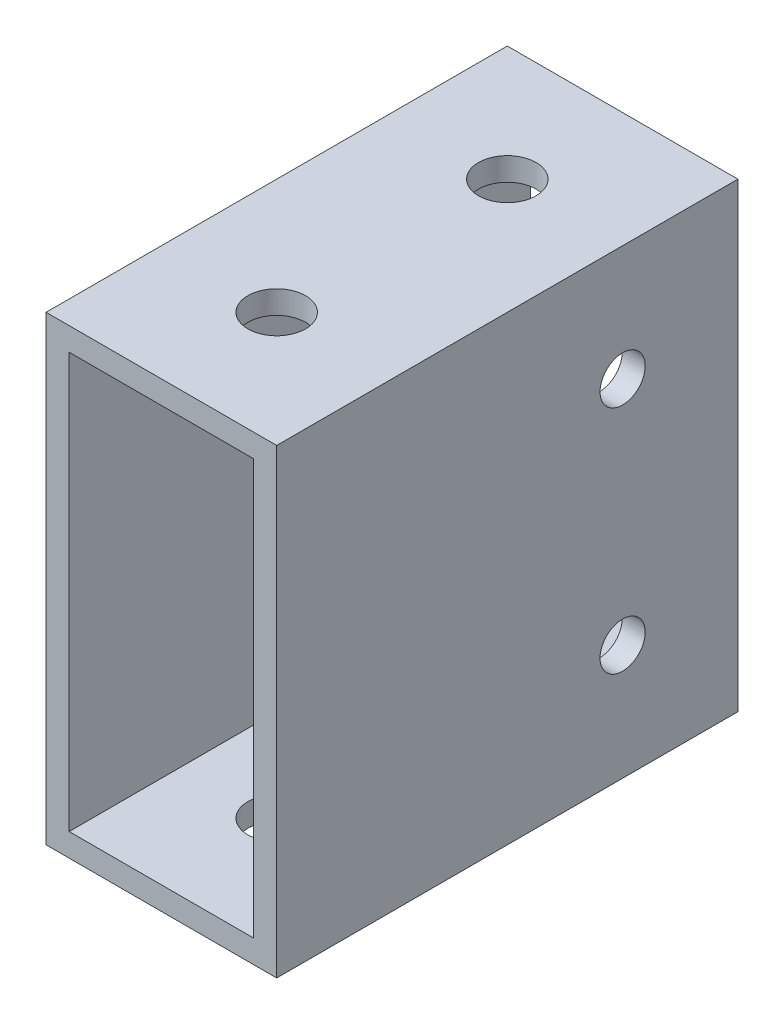
from build123d import *

# Parameters (mm, degrees)
SKETCH1_W           = 25.4
SKETCH1_H           = 50.8
SKETCH1_W_2         = 20.32
SKETCH1_H_2         = 45.72
EXTRUDE_THIN1_DEPTH = 25.4
SKETCH2_R           = 3.175
CUT_EXTRUDE1_DEPTH  = 51.8
SKETCH3_R           = 2.4892
CUT_EXTRUDE2_DEPTH  = 26.4


with BuildPart() as part:
    # Sketch1 → Extrude-Thin1 (new body, symmetric)
    with BuildSketch(Plane.XY):
        Rectangle(SKETCH1_W, SKETCH1_H)
        Rectangle(SKETCH1_W_2, SKETCH1_H_2, mode=Mode.SUBTRACT)
    extrude(amount=EXTRUDE_THIN1_DEPTH, both=True)

    # Sketch2 → Cut-Extrude1 (cut, through all)
    with BuildSketch(Plane(origin=(0, 25.4, 0), x_dir=(1, 0, 0), z_dir=(0, 1, 0))):
        with Locations((0, 12.7)):
            Circle(SKETCH2_R)
        with Locations((0, -12.7)):
            Circle(SKETCH2_R)
    extrude(amount=-CUT_EXTRUDE1_DEPTH, mode=Mode.SUBTRACT)

    # Sketch3 → Cut-Extrude2 (cut, through all)
    with BuildSketch(Plane(origin=(12.7, 0, 0), x_dir=(0, 0, -1), z_dir=(1, 0, 0))):
        with Locations((12.7, 12.7)):
            Circle(SKETCH3_R)
        with Locations((12.7, -12.7)):
            Circle(SKETCH3_R)
    extrude(amount=-CUT_EXTRUDE2_DEPTH, mode=Mode.SUBTRACT)


solid = part.part
